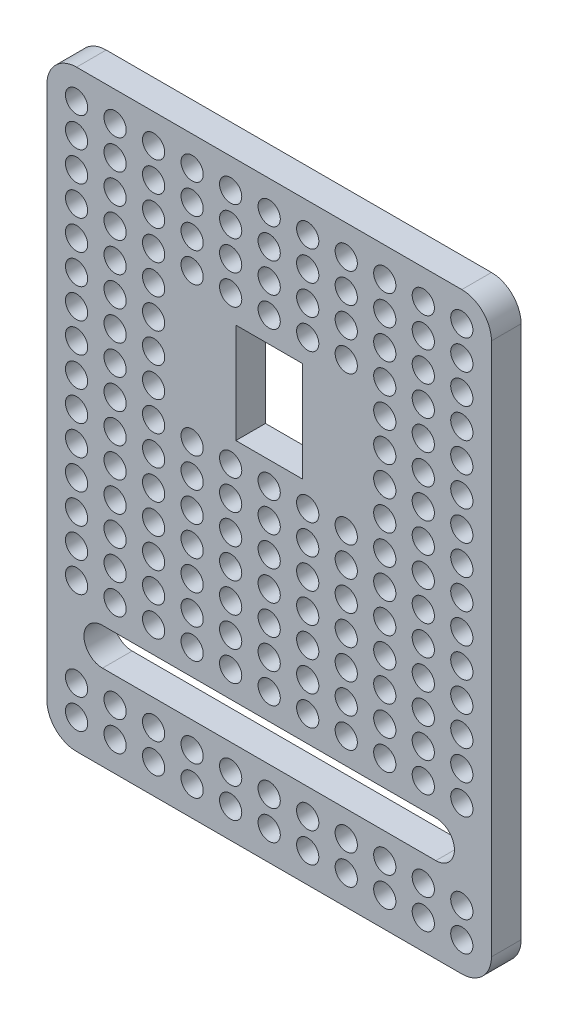
from build123d import *

# Parameters (mm, degrees)
EXTRUDE_1_DEPTH     = 4
CUT_EXTRUDE_1_DEPTH = 4
SKETCH_3_R          = 1.5
CUT_EXTRUDE_2_DEPTH = 4
SKETCH_5_W          = 9
SKETCH_5_H          = 13.5
CUT_EXTRUDE_6_DEPTH = 17


with BuildPart() as part:
    # Эскиз1 → Бобышка-Вытянуть1 (new body)
    with BuildSketch(Plane.XY):
        with BuildLine():
            Line((4, 0), (56, 0))
            ThreePointArc((56, 0), (58.828427125, 1.171572875), (60, 4))
            Line((60, 4), (60, 76))
            ThreePointArc((60, 76), (58.828427125, 78.828427125), (56, 80))
            Line((56, 80), (4, 80))
            ThreePointArc((4, 80), (1.171572875, 78.828427125), (0, 76))
            Line((0, 76), (0, 4))
            ThreePointArc((0, 4), (1.171572875, 1.171572875), (4, 0))
        make_face()
    extrude(amount=EXTRUDE_1_DEPTH)

    # Эскиз2 → Вырез-Вытянуть1 (cut)
    with BuildSketch(Plane.XY.offset(4)):
        with BuildLine():
            Line((7.5, 16.5), (52.5, 16.5))
            ThreePointArc((52.5, 16.5), (55, 14), (52.5, 11.5))
            Line((52.5, 11.5), (7.5, 11.5))
            ThreePointArc((7.5, 11.5), (5, 14), (7.5, 16.5))
        make_face()
    extrude(amount=-CUT_EXTRUDE_1_DEPTH, mode=Mode.SUBTRACT)

    # Эскиз3 → Вырез-Вытянуть2 (cut)
    with BuildSketch(Plane.XY.offset(4)):
        with Locations((4, 76)):
            Circle(SKETCH_3_R)
        with Locations((9.2, 76)):
            Circle(SKETCH_3_R)
        with Locations((14.4, 76)):
            Circle(SKETCH_3_R)
        with Locations((19.6, 76)):
            Circle(SKETCH_3_R)
        with Locations((24.8, 76)):
            Circle(SKETCH_3_R)
        with Locations((30, 76)):
            Circle(SKETCH_3_R)
        with Locations((35.2, 76)):
            Circle(SKETCH_3_R)
        with Locations((40.4, 76)):
            Circle(SKETCH_3_R)
        with Locations((45.6, 76)):
            Circle(SKETCH_3_R)
        with Locations((50.8, 76)):
            Circle(SKETCH_3_R)
        with Locations((56, 76)):
            Circle(SKETCH_3_R)
        with Locations((4, 72)):
            Circle(SKETCH_3_R)
        with Locations((9.2, 72)):
            Circle(SKETCH_3_R)
        with Locations((14.4, 72)):
            Circle(SKETCH_3_R)
        with Locations((19.6, 72)):
            Circle(SKETCH_3_R)
        with Locations((24.8, 72)):
            Circle(SKETCH_3_R)
        with Locations((30, 72)):
            Circle(SKETCH_3_R)
        with Locations((35.2, 72)):
            Circle(SKETCH_3_R)
        with Locations((40.4, 72)):
            Circle(SKETCH_3_R)
        with Locations((45.6, 72)):
            Circle(SKETCH_3_R)
        with Locations((50.8, 72)):
            Circle(SKETCH_3_R)
        with Locations((56, 72)):
            Circle(SKETCH_3_R)
        with Locations((4, 68)):
            Circle(SKETCH_3_R)
        with Locations((9.2, 68)):
            Circle(SKETCH_3_R)
        with Locations((14.4, 68)):
            Circle(SKETCH_3_R)
        with Locations((19.6, 68)):
            Circle(SKETCH_3_R)
        with Locations((24.8, 68)):
            Circle(SKETCH_3_R)
        with Locations((30, 68)):
            Circle(SKETCH_3_R)
        with Locations((35.2, 68)):
            Circle(SKETCH_3_R)
        with Locations((40.4, 68)):
            Circle(SKETCH_3_R)
        with Locations((45.6, 68)):
            Circle(SKETCH_3_R)
        with Locations((50.8, 68)):
            Circle(SKETCH_3_R)
        with Locations((56, 68)):
            Circle(SKETCH_3_R)
        with Locations((4, 64)):
            Circle(SKETCH_3_R)
        with Locations((9.2, 64)):
            Circle(SKETCH_3_R)
        with Locations((14.4, 64)):
            Circle(SKETCH_3_R)
        with Locations((19.6, 64)):
            Circle(SKETCH_3_R)
        with Locations((24.8, 64)):
            Circle(SKETCH_3_R)
        with Locations((30, 64)):
            Circle(SKETCH_3_R)
        with Locations((35.2, 64)):
            Circle(SKETCH_3_R)
        with Locations((40.4, 64)):
            Circle(SKETCH_3_R)
        with Locations((45.6, 64)):
            Circle(SKETCH_3_R)
        with Locations((50.8, 64)):
            Circle(SKETCH_3_R)
        with Locations((56, 64)):
            Circle(SKETCH_3_R)
        with Locations((4, 60)):
            Circle(SKETCH_3_R)
        with Locations((9.2, 60)):
            Circle(SKETCH_3_R)
        with Locations((14.4, 60)):
            Circle(SKETCH_3_R)
        with Locations((45.6, 60)):
            Circle(SKETCH_3_R)
        with Locations((50.8, 60)):
            Circle(SKETCH_3_R)
        with Locations((56, 60)):
            Circle(SKETCH_3_R)
        with Locations((4, 56)):
            Circle(SKETCH_3_R)
        with Locations((9.2, 56)):
            Circle(SKETCH_3_R)
        with Locations((14.4, 56)):
            Circle(SKETCH_3_R)
        with Locations((45.6, 56)):
            Circle(SKETCH_3_R)
        with Locations((50.8, 56)):
            Circle(SKETCH_3_R)
        with Locations((56, 56)):
            Circle(SKETCH_3_R)
        with Locations((4, 52)):
            Circle(SKETCH_3_R)
        with Locations((9.2, 52)):
            Circle(SKETCH_3_R)
        with Locations((14.4, 52)):
            Circle(SKETCH_3_R)
        with Locations((45.6, 52)):
            Circle(SKETCH_3_R)
        with Locations((50.8, 52)):
            Circle(SKETCH_3_R)
        with Locations((56, 52)):
            Circle(SKETCH_3_R)
        with Locations((4, 48)):
            Circle(SKETCH_3_R)
        with Locations((9.2, 48)):
            Circle(SKETCH_3_R)
        with Locations((14.4, 48)):
            Circle(SKETCH_3_R)
        with Locations((45.6, 48)):
            Circle(SKETCH_3_R)
        with Locations((50.8, 48)):
            Circle(SKETCH_3_R)
        with Locations((56, 48)):
            Circle(SKETCH_3_R)
        with Locations((4, 44)):
            Circle(SKETCH_3_R)
        with Locations((9.2, 44)):
            Circle(SKETCH_3_R)
        with Locations((14.4, 44)):
            Circle(SKETCH_3_R)
        with Locations((19.6, 44)):
            Circle(SKETCH_3_R)
        with Locations((24.8, 44)):
            Circle(SKETCH_3_R)
        with Locations((30, 44)):
            Circle(SKETCH_3_R)
        with Locations((35.2, 44)):
            Circle(SKETCH_3_R)
        with Locations((40.4, 44)):
            Circle(SKETCH_3_R)
        with Locations((45.6, 44)):
            Circle(SKETCH_3_R)
        with Locations((50.8, 44)):
            Circle(SKETCH_3_R)
        with Locations((56, 44)):
            Circle(SKETCH_3_R)
        with Locations((4, 40)):
            Circle(SKETCH_3_R)
        with Locations((9.2, 40)):
            Circle(SKETCH_3_R)
        with Locations((14.4, 40)):
            Circle(SKETCH_3_R)
        with Locations((19.6, 40)):
            Circle(SKETCH_3_R)
        with Locations((24.8, 40)):
            Circle(SKETCH_3_R)
        with Locations((30, 40)):
            Circle(SKETCH_3_R)
        with Locations((35.2, 40)):
            Circle(SKETCH_3_R)
        with Locations((40.4, 40)):
            Circle(SKETCH_3_R)
        with Locations((45.6, 40)):
            Circle(SKETCH_3_R)
        with Locations((50.8, 40)):
            Circle(SKETCH_3_R)
        with Locations((56, 40)):
            Circle(SKETCH_3_R)
        with Locations((4, 36)):
            Circle(SKETCH_3_R)
        with Locations((9.2, 36)):
            Circle(SKETCH_3_R)
        with Locations((14.4, 36)):
            Circle(SKETCH_3_R)
        with Locations((19.6, 36)):
            Circle(SKETCH_3_R)
        with Locations((24.8, 36)):
            Circle(SKETCH_3_R)
        with Locations((30, 36)):
            Circle(SKETCH_3_R)
        with Locations((35.2, 36)):
            Circle(SKETCH_3_R)
        with Locations((40.4, 36)):
            Circle(SKETCH_3_R)
        with Locations((45.6, 36)):
            Circle(SKETCH_3_R)
        with Locations((50.8, 36)):
            Circle(SKETCH_3_R)
        with Locations((56, 36)):
            Circle(SKETCH_3_R)
        with Locations((4, 32)):
            Circle(SKETCH_3_R)
        with Locations((9.2, 32)):
            Circle(SKETCH_3_R)
        with Locations((14.4, 32)):
            Circle(SKETCH_3_R)
        with Locations((19.6, 32)):
            Circle(SKETCH_3_R)
        with Locations((24.8, 32)):
            Circle(SKETCH_3_R)
        with Locations((30, 32)):
            Circle(SKETCH_3_R)
        with Locations((35.2, 32)):
            Circle(SKETCH_3_R)
        with Locations((40.4, 32)):
            Circle(SKETCH_3_R)
        with Locations((45.6, 32)):
            Circle(SKETCH_3_R)
        with Locations((50.8, 32)):
            Circle(SKETCH_3_R)
        with Locations((56, 32)):
            Circle(SKETCH_3_R)
        with Locations((4, 28)):
            Circle(SKETCH_3_R)
        with Locations((9.2, 28)):
            Circle(SKETCH_3_R)
        with Locations((14.4, 28)):
            Circle(SKETCH_3_R)
        with Locations((19.6, 28)):
            Circle(SKETCH_3_R)
        with Locations((24.8, 28)):
            Circle(SKETCH_3_R)
        with Locations((30, 28)):
            Circle(SKETCH_3_R)
        with Locations((35.2, 28)):
            Circle(SKETCH_3_R)
        with Locations((40.4, 28)):
            Circle(SKETCH_3_R)
        with Locations((45.6, 28)):
            Circle(SKETCH_3_R)
        with Locations((50.8, 28)):
            Circle(SKETCH_3_R)
        with Locations((56, 28)):
            Circle(SKETCH_3_R)
        with Locations((4, 24)):
            Circle(SKETCH_3_R)
        with Locations((9.2, 24)):
            Circle(SKETCH_3_R)
        with Locations((14.4, 24)):
            Circle(SKETCH_3_R)
        with Locations((19.6, 24)):
            Circle(SKETCH_3_R)
        with Locations((24.8, 24)):
            Circle(SKETCH_3_R)
        with Locations((30, 24)):
            Circle(SKETCH_3_R)
        with Locations((35.2, 24)):
            Circle(SKETCH_3_R)
        with Locations((40.4, 24)):
            Circle(SKETCH_3_R)
        with Locations((45.6, 24)):
            Circle(SKETCH_3_R)
        with Locations((50.8, 24)):
            Circle(SKETCH_3_R)
        with Locations((56, 24)):
            Circle(SKETCH_3_R)
        with Locations((4, 20)):
            Circle(SKETCH_3_R)
        with Locations((9.2, 20)):
            Circle(SKETCH_3_R)
        with Locations((14.4, 20)):
            Circle(SKETCH_3_R)
        with Locations((19.6, 20)):
            Circle(SKETCH_3_R)
        with Locations((24.8, 20)):
            Circle(SKETCH_3_R)
        with Locations((30, 20)):
            Circle(SKETCH_3_R)
        with Locations((35.2, 20)):
            Circle(SKETCH_3_R)
        with Locations((40.4, 20)):
            Circle(SKETCH_3_R)
        with Locations((45.6, 20)):
            Circle(SKETCH_3_R)
        with Locations((50.8, 20)):
            Circle(SKETCH_3_R)
        with Locations((56, 20)):
            Circle(SKETCH_3_R)
        with Locations((4, 8)):
            Circle(SKETCH_3_R)
        with Locations((9.2, 8)):
            Circle(SKETCH_3_R)
        with Locations((14.4, 8)):
            Circle(SKETCH_3_R)
        with Locations((19.6, 8)):
            Circle(SKETCH_3_R)
        with Locations((24.8, 8)):
            Circle(SKETCH_3_R)
        with Locations((30, 8)):
            Circle(SKETCH_3_R)
        with Locations((35.2, 8)):
            Circle(SKETCH_3_R)
        with Locations((40.4, 8)):
            Circle(SKETCH_3_R)
        with Locations((45.6, 8)):
            Circle(SKETCH_3_R)
        with Locations((50.8, 8)):
            Circle(SKETCH_3_R)
        with Locations((56, 8)):
            Circle(SKETCH_3_R)
        with Locations((4, 4)):
            Circle(SKETCH_3_R)
        with Locations((9.2, 4)):
            Circle(SKETCH_3_R)
        with Locations((14.4, 4)):
            Circle(SKETCH_3_R)
        with Locations((19.6, 4)):
            Circle(SKETCH_3_R)
        with Locations((24.8, 4)):
            Circle(SKETCH_3_R)
        with Locations((30, 4)):
            Circle(SKETCH_3_R)
        with Locations((35.2, 4)):
            Circle(SKETCH_3_R)
        with Locations((40.4, 4)):
            Circle(SKETCH_3_R)
        with Locations((45.6, 4)):
            Circle(SKETCH_3_R)
        with Locations((50.8, 4)):
            Circle(SKETCH_3_R)
        with Locations((56, 4)):
            Circle(SKETCH_3_R)
    extrude(amount=-CUT_EXTRUDE_2_DEPTH, mode=Mode.SUBTRACT)

    # Эскиз5 → Вырез-Вытянуть6 (cut)
    with BuildSketch(Plane.XY.offset(4)):
        with Locations((30, 53.85)):
            Rectangle(SKETCH_5_W, SKETCH_5_H)
    extrude(amount=-CUT_EXTRUDE_6_DEPTH, mode=Mode.SUBTRACT)


solid = part.part
